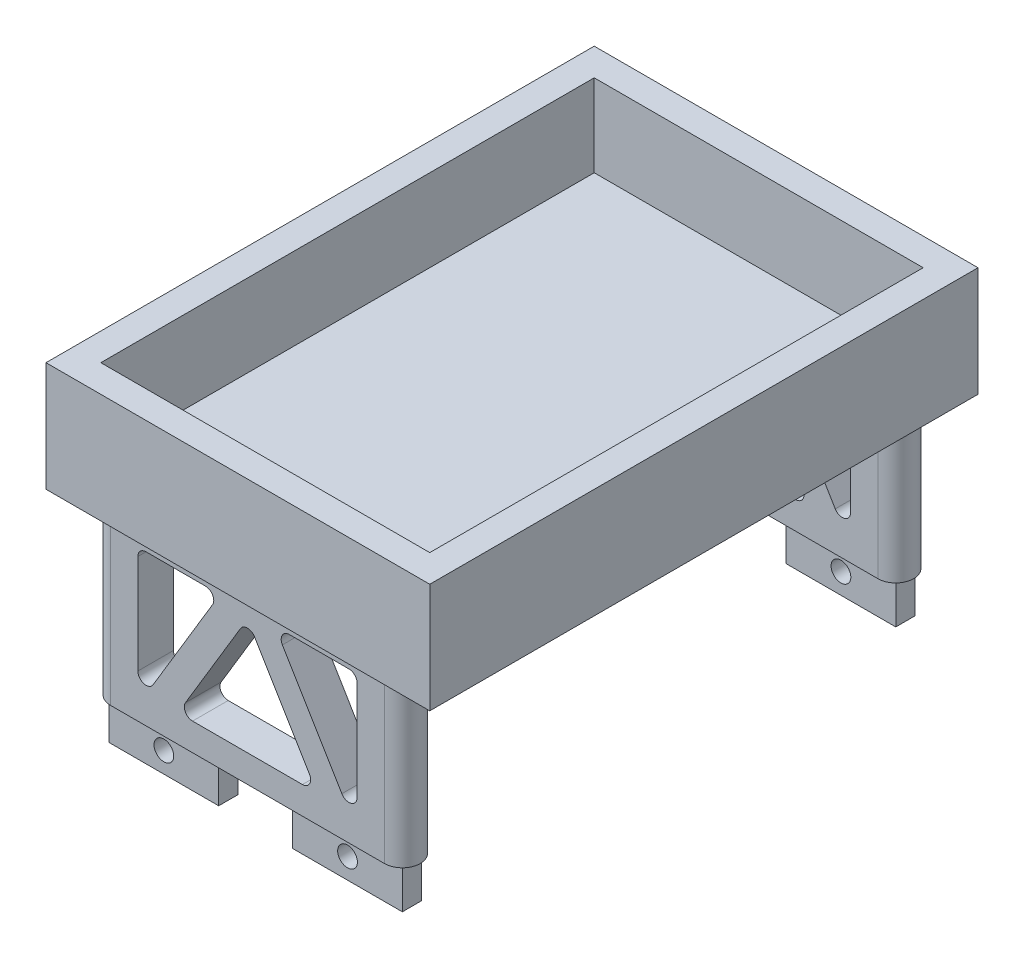
from build123d import *

# Parameters (mm, degrees)
SKETCH1_W             = 20
SKETCH1_H             = 3.5
BOSS_EXTRUDE1_DEPTH   = 7.5
BOSS_EXTRUDE1_2_DEPTH = 7.5
BOSS_EXTRUDE1_3_DEPTH = 7.5
BOSS_EXTRUDE1_4_DEPTH = 7.5
SKETCH2_R             = 3.25
BOSS_EXTRUDE2_DEPTH   = 30
BOSS_EXTRUDE2_2_DEPTH = 30
BOSS_EXTRUDE2_3_DEPTH = 30
BOSS_EXTRUDE2_4_DEPTH = 30
SKETCH3_W             = 70
SKETCH3_H             = 100
BOSS_EXTRUDE3_DEPTH   = 20
SKETCH4_W             = 60
SKETCH4_H             = 90
CUT_EXTRUDE1_DEPTH    = 15
SKETCH5_W             = 50
SKETCH5_H             = 30
BOSS_EXTRUDE4_DEPTH   = 6.5
FILLET2_R             = 1.5
SKETCH7_R             = 1.8
CUT_EXTRUDE2_DEPTH    = 93.5


with BuildPart() as part:
    # Sketch1 → Boss-Extrude1 (new body)
    with BuildSketch(Plane(origin=(0, 0, 0), x_dir=(1, 0, 0), z_dir=(0, 1, 0))):
        with Locations((-44.134164605, 23.547689378)):
            Rectangle(SKETCH1_W, SKETCH1_H)
    extrude(amount=BOSS_EXTRUDE1_DEPTH)


with BuildPart() as body_2:
    # Sketch1 → Boss-Extrude1 2 (new body)
    with BuildSketch(Plane(origin=(0, 0, 0), x_dir=(1, 0, 0), z_dir=(0, 1, 0))):
        with Locations((-10.634164605, 23.547689378)):
            Rectangle(SKETCH1_W, SKETCH1_H)
    extrude(amount=BOSS_EXTRUDE1_2_DEPTH)


with BuildPart() as body_3:
    # Sketch1 → Boss-Extrude1 3 (new body)
    with BuildSketch(Plane(origin=(0, 0, 0), x_dir=(1, 0, 0), z_dir=(0, 1, 0))):
        with Locations((-44.134164605, -66.452310622)):
            Rectangle(SKETCH1_W, SKETCH1_H)
    extrude(amount=BOSS_EXTRUDE1_3_DEPTH)


with BuildPart() as body_4:
    # Sketch1 → Boss-Extrude1 4 (new body)
    with BuildSketch(Plane(origin=(0, 0, 0), x_dir=(1, 0, 0), z_dir=(0, 1, 0))):
        with Locations((-10.634164605, -66.452310622)):
            Rectangle(SKETCH1_W, SKETCH1_H)
    extrude(amount=BOSS_EXTRUDE1_4_DEPTH)


with BuildPart() as body_5:
    # Sketch2 → Boss-Extrude2 (new body)
    with BuildSketch(Plane(origin=(0, 7.5, 0), x_dir=(1, 0, 0), z_dir=(0, 1, 0))):
        with Locations((-2.384164605, -66.452310622)):
            Circle(SKETCH2_R)
    extrude(amount=BOSS_EXTRUDE2_DEPTH)


with BuildPart() as body_6:
    # Sketch2 → Boss-Extrude2 2 (new body)
    with BuildSketch(Plane(origin=(0, 7.5, 0), x_dir=(1, 0, 0), z_dir=(0, 1, 0))):
        with Locations((-52.384164605, 23.547689378)):
            Circle(SKETCH2_R)
    extrude(amount=BOSS_EXTRUDE2_2_DEPTH)


with BuildPart() as body_7:
    # Sketch2 → Boss-Extrude2 3 (new body)
    with BuildSketch(Plane(origin=(0, 7.5, 0), x_dir=(1, 0, 0), z_dir=(0, 1, 0))):
        with Locations((-2.384164605, 23.547689378)):
            Circle(SKETCH2_R)
    extrude(amount=BOSS_EXTRUDE2_3_DEPTH)


with BuildPart() as body_8:
    # Sketch2 → Boss-Extrude2 4 (new body)
    with BuildSketch(Plane(origin=(0, 7.5, 0), x_dir=(1, 0, 0), z_dir=(0, 1, 0))):
        with Locations((-52.384164605, -66.452310622)):
            Circle(SKETCH2_R)
    extrude(amount=BOSS_EXTRUDE2_4_DEPTH)


with BuildPart() as body_9:
    # Sketch3 → Boss-Extrude3 (new body)
    with BuildSketch(Plane(origin=(0, 37.5, 0), x_dir=(1, 0, 0), z_dir=(0, 1, 0))):
        with Locations((-27.384164605, -21.452310622)):
            Rectangle(SKETCH3_W, SKETCH3_H)
    extrude(amount=BOSS_EXTRUDE3_DEPTH)

    # Sketch4 → Cut-Extrude1 (cut)
    with BuildSketch(Plane(origin=(0, 57.5, 0), x_dir=(1, 0, 0), z_dir=(0, 1, 0))):
        with Locations((-27.384164605, -21.452310622)):
            Rectangle(SKETCH4_W, SKETCH4_H)
    extrude(amount=-CUT_EXTRUDE1_DEPTH, mode=Mode.SUBTRACT)

    # Sketch5 → Boss-Extrude4 (add)
    with BuildSketch(Plane.XY.offset(69.702310622)):
        with Locations((-27.384164605, 22.5)):
            Rectangle(SKETCH5_W, SKETCH5_H)
        Polygon((-47.384164605, 35), (-32.384164605, 35), (-47.384164605, 10), align=None, mode=Mode.SUBTRACT)
        Polygon((-7.384164605, 10), (-7.384164605, 35), (-22.384164605, 35), align=None, mode=Mode.SUBTRACT)
        Polygon((-27.384164605, 33.615080175), (-40.05321271, 12.5), (-14.7151165, 12.5), align=None, mode=Mode.SUBTRACT)
    boss_extrude4 = extrude(amount=-BOSS_EXTRUDE4_DEPTH)

    # Mirror1: Boss-Extrude4 across plane
    add(boss_extrude4.mirror(Plane(origin=(0, 0, 21.452310622), x_dir=(1, 0, 0), z_dir=(0, 0, -1))))

    # Fillet2
    fillet2_edges = [body_9.edges().sort_by_distance(p)[0] for p in [
        (-47.384164605, 35, 66.452310622),
        (-32.384164605, 35, 66.452310622),
        (-47.384164605, 10, 66.452310622),
        (-22.384164605, 35, 66.452310622),
        (-7.384164605, 35, 66.452310622),
        (-7.384164605, 10, 66.452310622),
        (-14.7151165, 12.5, 66.452310622),
        (-40.05321271, 12.5, 66.452310622),
        (-27.384164605, 33.615080175, 66.452310622),
        (-47.384164605, 10, -23.547689378),
        (-32.384164605, 35, -23.547689378),
        (-47.384164605, 35, -23.547689378),
        (-7.384164605, 10, -23.547689378),
        (-7.384164605, 35, -23.547689378),
        (-22.384164605, 35, -23.547689378),
        (-27.384164605, 33.615080175, -23.547689378),
        (-40.05321271, 12.5, -23.547689378),
        (-14.7151165, 12.5, -23.547689378),
    ]]
    fillet(fillet2_edges, radius=FILLET2_R)


with BuildPart() as cut_extrude2_tool:
    # Sketch7 → Cut-Extrude2 (new body)
    with BuildSketch(Plane.XY.offset(68.202310622)):
        with Locations((-44.134164605, 3.75)):
            Circle(SKETCH7_R)
    cut_extrude2 = extrude(amount=-CUT_EXTRUDE2_DEPTH)


with BuildPart() as part_1:
    add(part.part)

    # Cut-Extrude2: cut by cut_extrude2_tool
    add(cut_extrude2_tool.part, mode=Mode.SUBTRACT)


with BuildPart() as body_3_1:
    add(body_3.part)

    # Cut-Extrude2: cut by cut_extrude2_tool
    add(cut_extrude2_tool.part, mode=Mode.SUBTRACT)


with BuildPart() as mirror2_tool:
    # Mirror2: Cut-Extrude2 across plane
    add(cut_extrude2.mirror(Plane.ZY.offset(27.384164605)))


with BuildPart() as body_2_1:
    add(body_2.part)

    # Mirror2: cut by mirror2_tool
    add(mirror2_tool.part, mode=Mode.SUBTRACT)


with BuildPart() as body_4_1:
    add(body_4.part)

    # Mirror2: cut by mirror2_tool
    add(mirror2_tool.part, mode=Mode.SUBTRACT)


solid = Compound([body_5.part, body_6.part, body_7.part, body_8.part, body_9.part, part_1.part, body_3_1.part, body_2_1.part, body_4_1.part])
